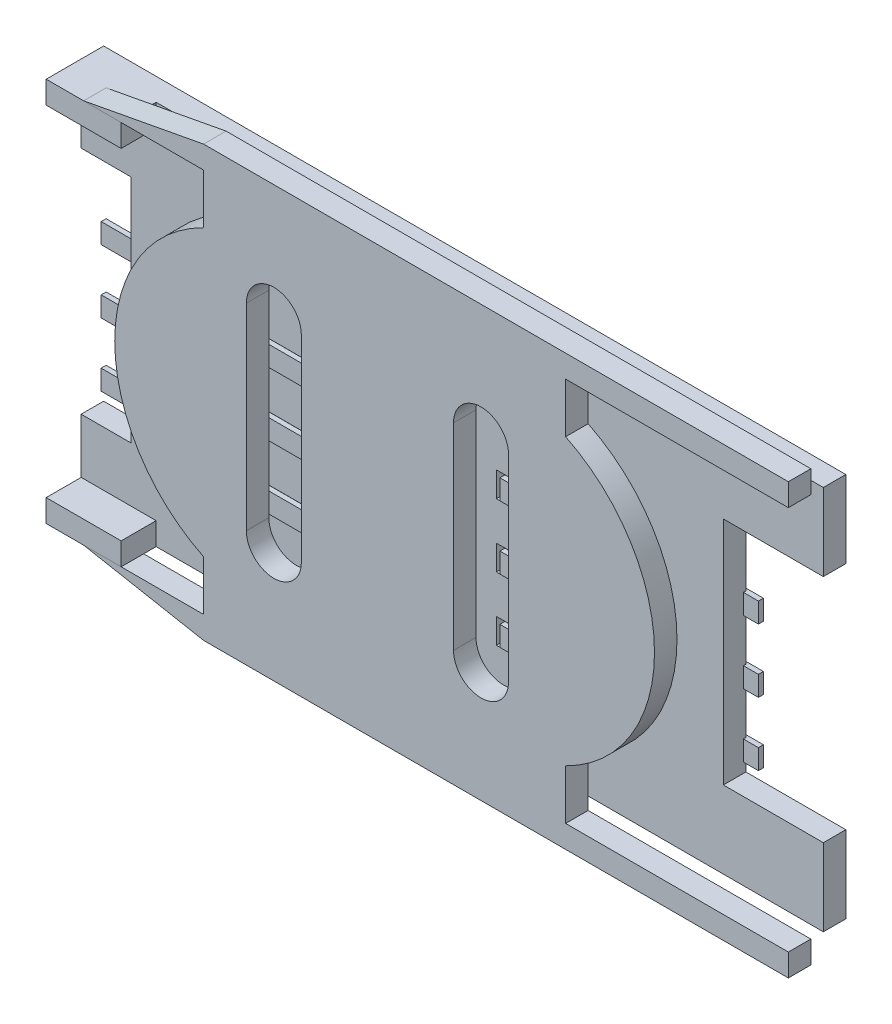
from build123d import *

# Parameters (mm, degrees)
SKETCH1_W             = 6.376063003
SKETCH1_H             = 1
SKETCH1_W_2           = 5.71073469
BOSS_EXTRUDE1_DEPTH   = 0.9
SKETCH4_W             = 3
SKETCH4_H             = 0.9
BOSS_EXTRUDE3_DEPTH   = 1.4
BOSS_EXTRUDE4_DEPTH   = 0.9
CUT_EXTRUDE1_DEPTH    = 0.9
EXTRUDE_THIN1_DEPTH   = 0.4
EXTRUDE_THIN1_2_DEPTH = 0.4
LPATTERN1_COUNT       = 3
LPATTERN1_PITCH       = 2.54


with BuildPart() as part:
    # Sketch1 → Boss-Extrude1 (new body)
    with BuildSketch(Plane.XY):
        Polygon((29.7, 12.31), (29.7, 15.4), (0, 15.4), (0, 12.31), (2, 12.31), (2, 3.09), (0, 3.09), (0, 0), (29.7, 0), (29.7, 3.09), (25.7, 3.09), (25.7, 12.31), align=None)
        with Locations((6.497879886, 3.89)):
            Rectangle(SKETCH1_W, SKETCH1_H, mode=Mode.SUBTRACT)
        with Locations((19.471781996, 3.89)):
            Rectangle(SKETCH1_W_2, SKETCH1_H, mode=Mode.SUBTRACT)
        with Locations((6.497879886, 6.43)):
            Rectangle(SKETCH1_W, SKETCH1_H, mode=Mode.SUBTRACT)
        with Locations((19.471781996, 6.43)):
            Rectangle(SKETCH1_W_2, SKETCH1_H, mode=Mode.SUBTRACT)
        with Locations((6.497879886, 8.97)):
            Rectangle(SKETCH1_W, SKETCH1_H, mode=Mode.SUBTRACT)
        with Locations((19.471781996, 8.97)):
            Rectangle(SKETCH1_W_2, SKETCH1_H, mode=Mode.SUBTRACT)
    extrude(amount=BOSS_EXTRUDE1_DEPTH)

    # Sketch4 → Boss-Extrude3 (add)
    with BuildSketch(Plane.XY.offset(0.9)):
        with Locations((1.5, 14.95)):
            Rectangle(SKETCH4_W, SKETCH4_H)
        with Locations((1.5, 0.45)):
            Rectangle(SKETCH4_W, SKETCH4_H)
    extrude(amount=BOSS_EXTRUDE3_DEPTH)


with BuildPart() as body_2:
    # Sketch5 → Boss-Extrude4 (new body)
    with BuildSketch(Plane(origin=(0, 0, 2.299999972), x_dir=(-1, 0, 0), z_dir=(0, 0, -1))):
        with BuildLine():
            Line((-6.299388257, -0.9), (-29.7, -0.9))
            Line((-29.7, -0.9), (-29.7, 0))
            Line((-29.7, 0), (-20.787621614, 0))
            Line((-20.787621614, 0), (-20.787621614, 1.997714143))
            ThreePointArc((-20.787621614, 1.997714143), (-24.343621614, 7.7), (-20.787621614, 13.402285857))
            Line((-20.787621614, 13.402285857), (-20.787621614, 15.4))
            Line((-20.787621614, 15.4), (-29.7, 15.4))
            Line((-29.7, 15.4), (-29.7, 16.3))
            Line((-29.7, 16.3), (-6.299388257, 16.3))
            Line((-6.299388257, 16.3), (-1.5, 15.4))
            Line((-1.5, 15.4), (-6.299388257, 15.4))
            Line((-6.299388257, 15.4), (-6.299388257, 13.402285857))
            ThreePointArc((-6.299388257, 13.402285857), (-2.743388257, 7.7), (-6.299388257, 1.997714143))
            Line((-6.299388257, 1.997714143), (-6.299388257, 0))
            Line((-6.299388257, 0), (-1.5, 0))
            Line((-1.5, 0), (-6.299388257, -0.9))
        make_face()
    extrude(amount=BOSS_EXTRUDE4_DEPTH)

    # Sketch6 → Cut-Extrude1 (cut)
    with BuildSketch(Plane.XY.offset(2.299999972)):
        with BuildLine():
            Line((16.301809517, 11.643437567), (16.301809517, 3.756562433))
            ThreePointArc((16.301809517, 3.756562433), (17.401636072, 2.656735878), (18.501462628, 3.756562433))
            Line((18.501462628, 3.756562433), (18.501462628, 11.643437567))
            ThreePointArc((18.501462628, 11.643437567), (17.401636072, 12.743264122), (16.301809517, 11.643437567))
        make_face()
        with BuildLine():
            Line((8.011008576, 11.643437567), (8.011008576, 3.756562433))
            ThreePointArc((8.011008576, 3.756562433), (9.110835131, 2.656735878), (10.210661686, 3.756562433))
            Line((10.210661686, 3.756562433), (10.210661686, 11.643437567))
            ThreePointArc((10.210661686, 11.643437567), (9.110835131, 12.743264122), (8.011008576, 11.643437567))
        make_face()
    extrude(amount=-CUT_EXTRUDE1_DEPTH, mode=Mode.SUBTRACT)


with BuildPart() as body_3:
    # Sketch7 → Extrude-Thin1 (new body, symmetric)
    with BuildSketch(Plane(origin=(0, 3.8853, 0), x_dir=(1, 0, 0), z_dir=(0, 1, 0))):
        with BuildLine():
            Line((0, -0.1), (5.742, -0.1))
            Line((5.742, -0.1), (5.742, -0.9))
            ThreePointArc((5.742, -0.9), (6.411878408, -1.618253316), (7.175021739, -1))
            Line((7.175021739, -1), (9.4442, -1))
            Line((9.4442, -1), (9.4442, -0.8))
            Line((9.4442, -0.8), (6.972294033, -0.8))
            ThreePointArc((6.972294033, -0.8), (6.512234962, -1.41756782), (5.942, -0.9))
            Line((5.942, -0.9), (5.942, 0.1))
            Line((5.942, 0.1), (0, 0.1))
            Line((0, 0.1), (0, -0.1))
        make_face()
    extrude_thin1 = extrude(amount=EXTRUDE_THIN1_DEPTH, both=True)


with BuildPart() as body_4:
    # Sketch7 → Extrude-Thin1 2 (new body, symmetric)
    with BuildSketch(Plane(origin=(0, 3.8853, 0), x_dir=(1, 0, 0), z_dir=(0, 1, 0))):
        with BuildLine():
            Line((26.302326038, 0.1), (20.360326038, 0.1))
            Line((20.360326038, 0.1), (20.360326038, -0.9))
            ThreePointArc((20.360326038, -0.9), (19.790091075, -1.41756782), (19.330032005, -0.8))
            Line((19.330032005, -0.8), (16.858126038, -0.8))
            Line((16.858126038, -0.8), (16.858126038, -1))
            Line((16.858126038, -1), (19.127304299, -1))
            ThreePointArc((19.127304299, -1), (19.89044763, -1.618253316), (20.560326038, -0.9))
            Line((20.560326038, -0.9), (20.560326038, -0.1))
            Line((20.560326038, -0.1), (26.302326038, -0.1))
            Line((26.302326038, -0.1), (26.302326038, 0.1))
        make_face()
    extrude_thin1_2 = extrude(amount=EXTRUDE_THIN1_2_DEPTH, both=True)


with BuildPart() as lpattern1_1:
    # LPattern1: Extrude-Thin1, Extrude-Thin1 2 ×3
    with Locations(*[(0, i * LPATTERN1_PITCH, 0) for i in range(1, LPATTERN1_COUNT)]):
        add(extrude_thin1)
        add(extrude_thin1_2)


solid = Compound([part.part, body_2.part, body_3.part, body_4.part, lpattern1_1.part])
